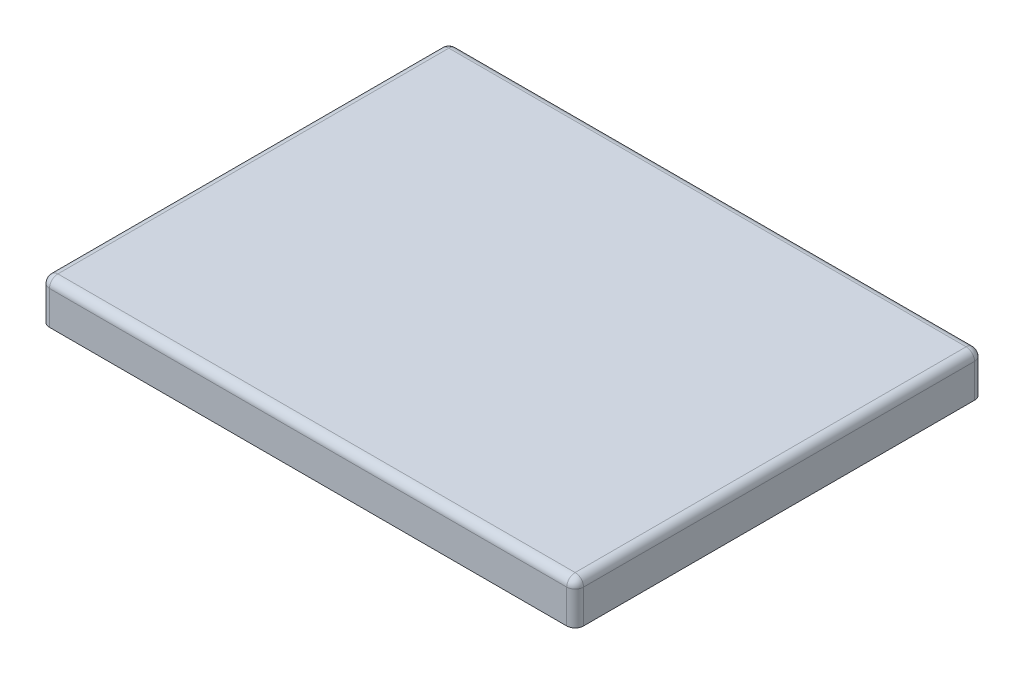
from build123d import *

# Parameters (mm, degrees)
SKETCH1_W           = 644.525
SKETCH1_H           = 492.125
SKETCH1_W_2         = 635
SKETCH1_H_2         = 482.6
BOSS_EXTRUDE1_DEPTH = 50.8
SKETCH2_W           = 492.125
SKETCH2_H           = 4.7625
BOSS_EXTRUDE2_DEPTH = 644.525
FILLET1_R           = 10.16


with BuildPart() as part:
    # Sketch1 → Boss-Extrude1 (new body)
    with BuildSketch(Plane(origin=(0, 0, 0), x_dir=(1, 0, 0), z_dir=(0, 1, 0))):
        Rectangle(SKETCH1_W, SKETCH1_H)
        Rectangle(SKETCH1_W_2, SKETCH1_H_2, mode=Mode.SUBTRACT)
    extrude(amount=BOSS_EXTRUDE1_DEPTH)

    # Sketch2 → Boss-Extrude2 (add)
    with BuildSketch(Plane(origin=(322.2625, 0, 0), x_dir=(0, 0, -1), z_dir=(1, 0, 0))):
        with Locations((0, 48.41875)):
            Rectangle(SKETCH2_W, SKETCH2_H)
    extrude(amount=-BOSS_EXTRUDE2_DEPTH)

    # Fillet1
    fillet1_edges = [part.edges().sort_by_distance(p)[0] for p in [
        (-322.2625, 50.8, 0),
        (0, 50.8, 246.0625),
        (322.2625, 50.8, 0),
        (0, 50.8, -246.0625),
        (322.2625, 25.4, 246.0625),
        (-322.2625, 25.4, 246.0625),
        (-322.2625, 25.4, -246.0625),
        (322.2625, 25.4, -246.0625),
    ]]
    fillet(fillet1_edges, radius=FILLET1_R)


solid = part.part
